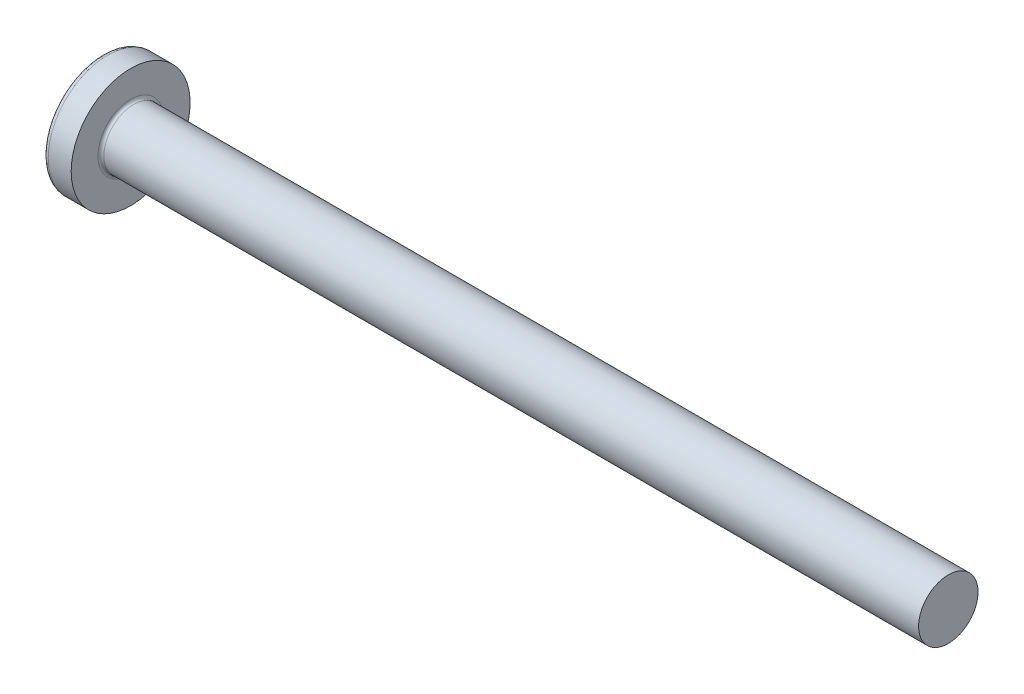
from build123d import *

# Parameters (mm, degrees)
FILLET1_R    = 0.2
SKETCH3_W    = 1.03
SKETCH3_H    = 4.3
SKETCH4_W    = 1.03
SKETCH4_H    = 1.966638464
RECPAT_COUNT = 2
RECPAT_ANGLE = 90


with BuildPart() as part:
    # BodySke → Base-Revolve (revolve)
    with BuildSketch(Plane.XY):
        with BuildLine():
            Line((3.1, 2), (3.1, 4))
            Line((3.1, 4), (1.555305874, 4))
            ThreePointArc((1.555305874, 4), (1.392873227, 3.961271902), (1.265388955, 3.853420195))
            ThreePointArc((1.265388955, 3.853420195), (0.324444487, 2.027933456), (0, 0))
            Line((0, 0), (58.1, 0))
            Line((58.1, 0), (58.1, 2))
            Line((58.1, 2), (3.1, 2))
        make_face()
    revolve(axis=Axis((-25.4, 0, 0), (1, 0, 0)))

    # Fillet1
    fillet1_edges = [part.edges().sort_by_distance(p)[0] for p in [
        (3.1, -2, 0),
    ]]
    fillet(fillet1_edges, radius=FILLET1_R)

    # Sketch3 → Recess section 0
    with BuildSketch(Plane(origin=(0, 0, 0), x_dir=(0, 0, -1), z_dir=(1, 0, 0))):
        Rectangle(SKETCH3_W, SKETCH3_H)
    # Sketch4 → Recess section 1
    with BuildSketch(Plane(origin=(2.34, 0, 0), x_dir=(0, 0, -1), z_dir=(1, 0, 0))):
        Rectangle(SKETCH4_W, SKETCH4_H)
    recess = loft(mode=Mode.SUBTRACT)

    # RecPat: Recess ×2 about axis
    recpat_axis = Axis((0, 0, 0), (1, 0, 0))
    for i in range(1, RECPAT_COUNT):
        add(recess.rotate(recpat_axis, i * RECPAT_ANGLE / (RECPAT_COUNT - 1)), mode=Mode.SUBTRACT)

    # RecCorSke → RecessCore (revolve, cut)
    with BuildSketch(Plane.XY):
        Polygon((0, 0), (0, 1.01462874), (2.34, 0.851), (2.616506661, 0), align=None)
    revolve(axis=Axis((-3.175, 0, 0), (1, 0, 0)), mode=Mode.SUBTRACT)


solid = part.part
